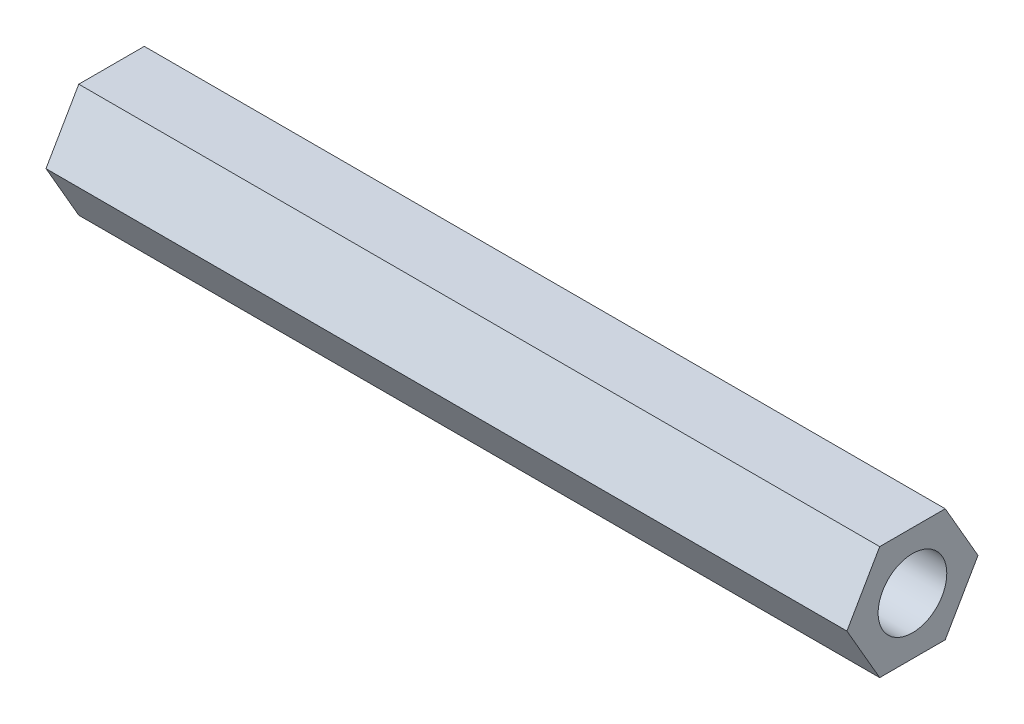
from build123d import *

# Parameters (mm, degrees)
SKETCH1_R           = 4.7625
BOSS_EXTRUDE1_DEPTH = 111.125


with BuildPart() as part:
    # Sketch1 → Boss-Extrude1 (new body)
    with BuildSketch(Plane(origin=(0, 0, 0), x_dir=(0, -1, 0), z_dir=(-1, 0, 0))):
        Polygon((7.874, -4.54605602), (7.874, 4.54605602), (0, 9.092112039), (-7.874, 4.54605602), (-7.874, -4.54605602), (0, -9.092112039), align=None)
        Circle(SKETCH1_R, mode=Mode.SUBTRACT)
    extrude(amount=-BOSS_EXTRUDE1_DEPTH)


solid = part.part
